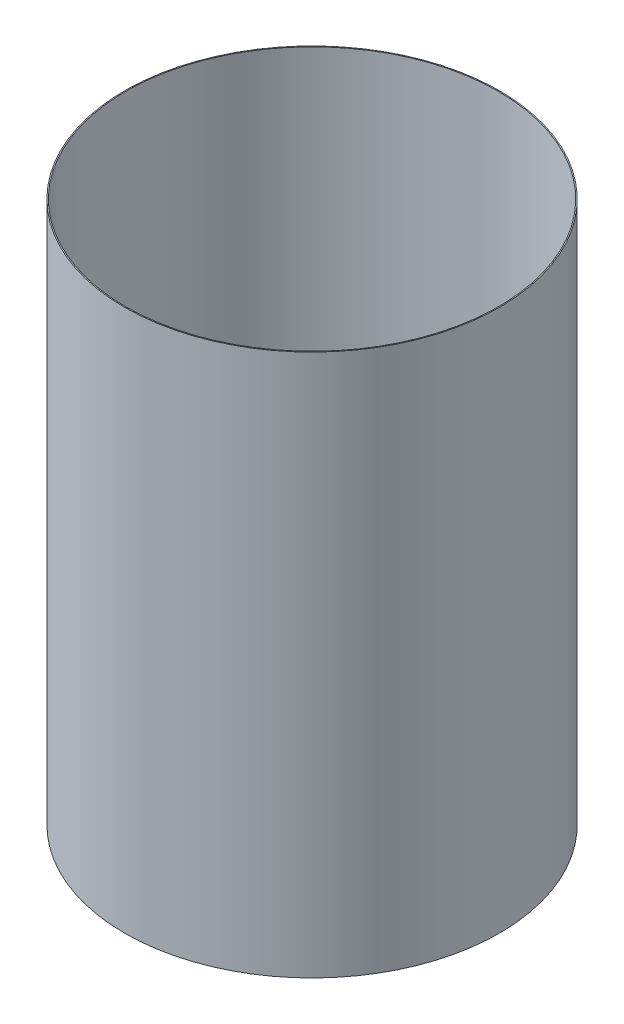
from build123d import *

# Parameters (mm, degrees)
SKETCH1_W = 0.254
SKETCH1_H = 133.35


with BuildPart() as part:
    # Sketch1 → Revolve-Thin1 (revolve)
    with BuildSketch(Plane.XY):
        with Locations((-45.9994, -86.580914232)):
            Rectangle(SKETCH1_W, SKETCH1_H)
    revolve(axis=Axis((0, 55, 0), (0, -1, 0)))


solid = part.part
